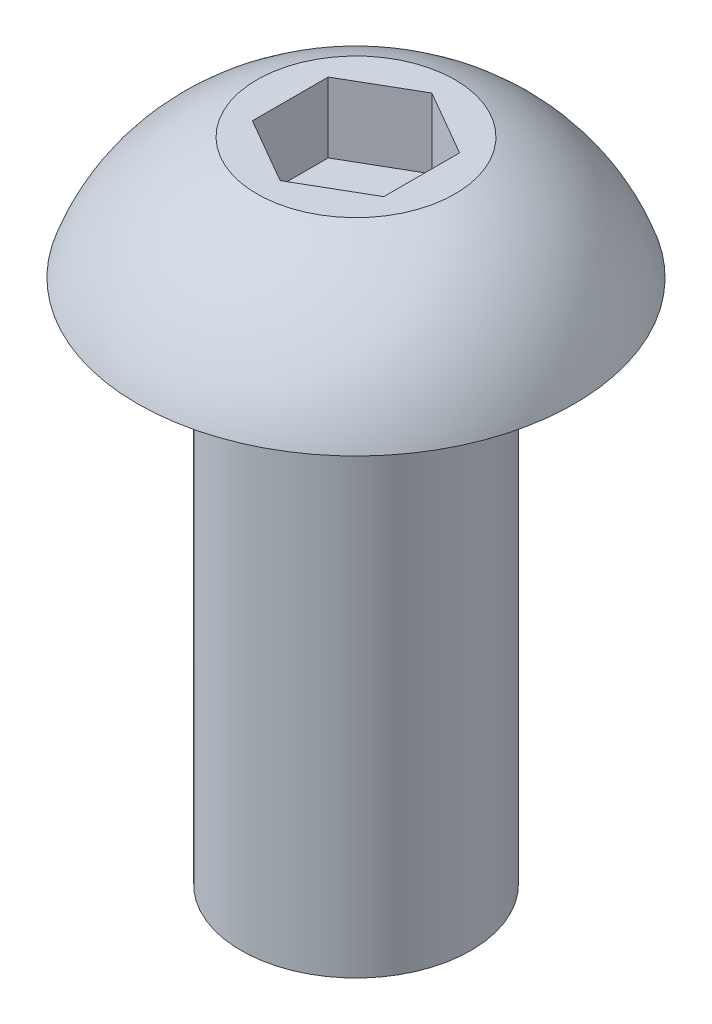
from build123d import *

# Parameters (mm, degrees)
CUT_EXTRUDE1_DEPTH = 1.27


with BuildPart() as part:
    # Sketch1 → Revolve1 (revolve)
    with BuildSketch(Plane.XY):
        with BuildLine():
            Line((-2.0828, 0), (-3.9624, 0))
            ThreePointArc((-3.9624, 0), (-3.131232795, 1.352726455), (-1.79477003, 2.2098))
            Line((-1.79477003, 2.2098), (0, 2.2098))
            Line((0, 2.2098), (0, -9.525))
            Line((0, -9.525), (-2.0828, -9.525))
            Line((-2.0828, -9.525), (-2.0828, 0))
        make_face()
    revolve(axis=Axis((0, -9.525, 0), (0, 1, 0)))

    # Sketch2 → Cut-Extrude1 (cut)
    with BuildSketch(Plane(origin=(0, 2.2098, 0), x_dir=(1, 0, 0), z_dir=(0, 1, 0))):
        Polygon((-1.190625, 0.687407664), (-1.190625, -0.687407664), (0, -1.374815329), (1.190625, -0.687407664), (1.190625, 0.687407664), (0, 1.374815329), align=None)
    extrude(amount=-CUT_EXTRUDE1_DEPTH, mode=Mode.SUBTRACT)


solid = part.part
